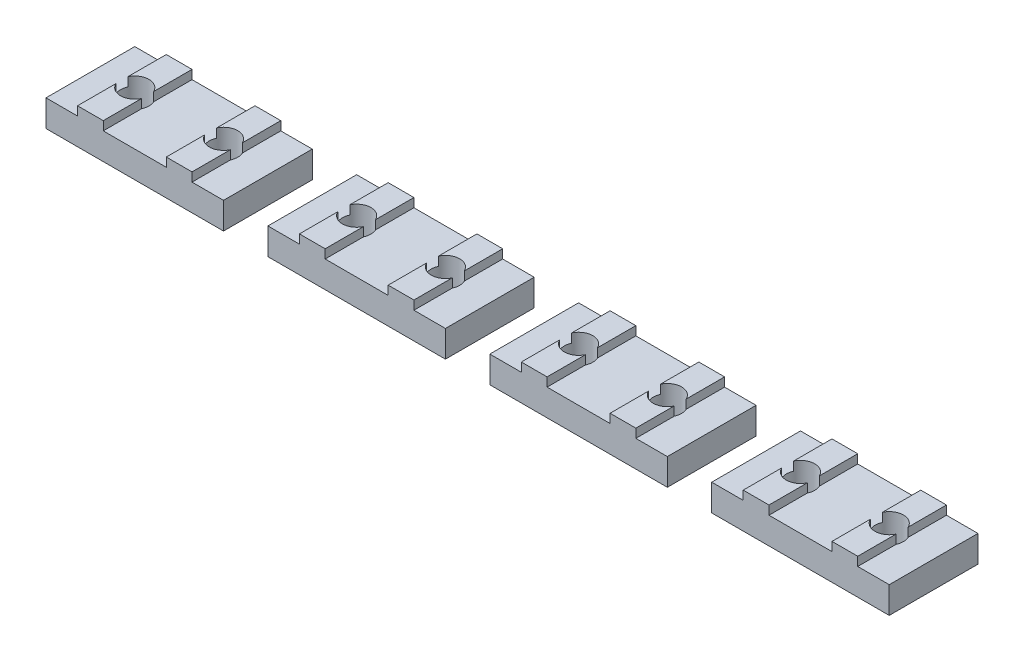
from build123d import *

# Parameters (mm, degrees)
MAIN_DEPTH                 = 10
ESQUISSE2_R                = 1.6
TOPHOLE_DEPTH              = 12.874342087
R_P_TITION_LIN_AIRE1_COUNT = 2
R_P_TITION_LIN_AIRE1_PITCH = 10
R_P_TITION_LIN_AIRE2_COUNT = 4
R_P_TITION_LIN_AIRE2_PITCH = 25


with BuildPart() as part:
    # Esquisse1 → Main (new body)
    with BuildSketch(Plane.XY):
        Polygon((-5, 0), (-5, 3), (-1.45, 3), (-1.45, 4), (1.45, 4), (1.45, 3), (5, 3), (5, 0), align=None)
    main = extrude(amount=MAIN_DEPTH)

    # Esquisse2 → TopHole (cut, through all)
    with BuildSketch(Plane(origin=(0, 4, 0), x_dir=(1, 0, 0), z_dir=(0, 1, 0))):
        with Locations((0, -5)):
            Circle(ESQUISSE2_R)
    tophole = extrude(amount=-TOPHOLE_DEPTH, mode=Mode.SUBTRACT)

    # Répétition linéaire1: Main, TopHole ×2
    with Locations(*[(-i * R_P_TITION_LIN_AIRE1_PITCH, 0, 0) for i in range(1, R_P_TITION_LIN_AIRE1_COUNT)]):
        add(main)
        add(tophole, mode=Mode.SUBTRACT)


with BuildPart() as r_p_tition_lin_aire2_1:
    # Répétition linéaire2: pattern copy
    add(part.part.moved(Location(Vector(-1, 0, 0) * (1 * R_P_TITION_LIN_AIRE2_PITCH))))


with BuildPart() as r_p_tition_lin_aire2_2:
    # Répétition linéaire2: pattern copy
    add(part.part.moved(Location(Vector(-1, 0, 0) * (2 * R_P_TITION_LIN_AIRE2_PITCH))))


with BuildPart() as r_p_tition_lin_aire2_3:
    # Répétition linéaire2: pattern copy
    add(part.part.moved(Location(Vector(-1, 0, 0) * (3 * R_P_TITION_LIN_AIRE2_PITCH))))


solid = Compound([part.part, r_p_tition_lin_aire2_1.part, r_p_tition_lin_aire2_2.part, r_p_tition_lin_aire2_3.part])
